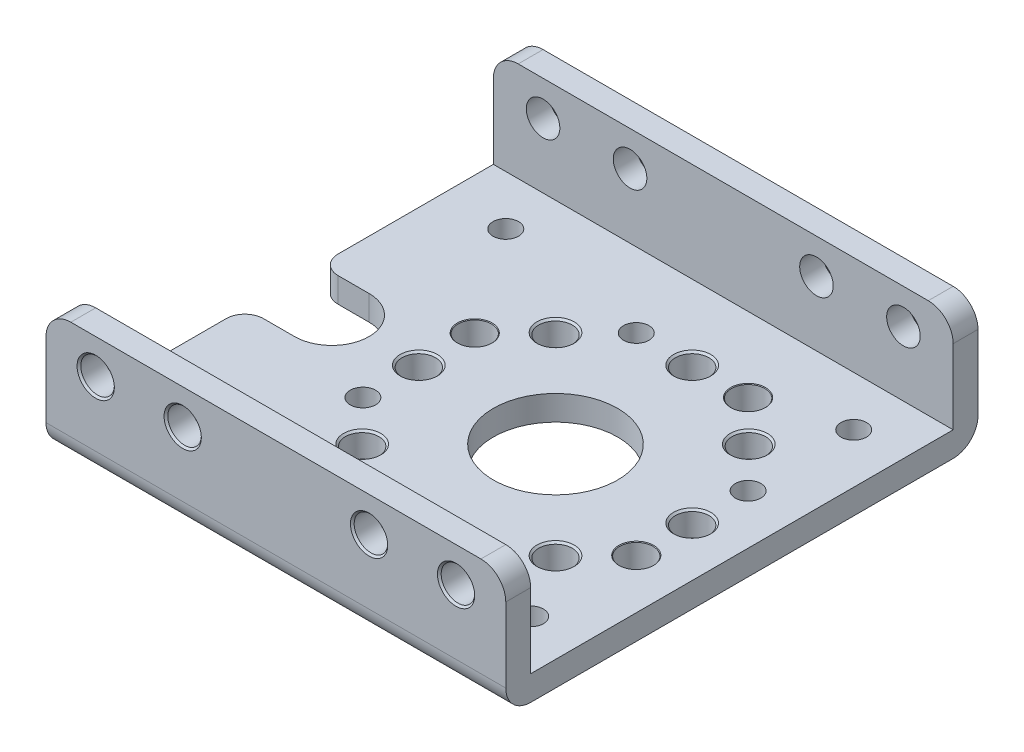
from build123d import *

# Parameters (mm, degrees)
SKETCH1_W           = 37
SKETCH1_H           = 38
BOSS_EXTRUDE1_DEPTH = 10
SKETCH2_W           = 34
SKETCH2_H           = 8
CUT_EXTRUDE1_DEPTH  = 38
CUT_EXTRUDE2_DEPTH  = 3
HOLE1_D             = 2.05
HOLE1_DEPTH         = 10
HOLE2_D             = 2.05
HOLE2_DEPTH         = 10
HOLE3_D             = 2.05
HOLE3_DEPTH         = 10
HOLE4_D             = 2.05
HOLE4_DEPTH         = 10
HOLE5_D             = 2.05
HOLE5_DEPTH         = 10
HOLE6_D             = 2.05
HOLE6_DEPTH         = 10
HOLE7_D             = 2.05
HOLE7_DEPTH         = 10
HOLE8_D             = 2.05
HOLE8_DEPTH         = 10
HOLE9_D             = 10
HOLE9_DEPTH         = 10
HOLE10_D            = 2.7
HOLE10_DEPTH        = 2
HOLE11_D            = 2.7
HOLE11_DEPTH        = 2
HOLE12_D            = 2.7
HOLE12_DEPTH        = 2
HOLE13_D            = 2.7
HOLE13_DEPTH        = 2
HOLE14_D            = 2.7
HOLE14_DEPTH        = 2
HOLE15_D            = 2.7
HOLE15_DEPTH        = 2
HOLE16_D            = 2.7
HOLE16_DEPTH        = 2
HOLE17_D            = 2.7
HOLE17_DEPTH        = 2
HOLE18_D            = 2.7
HOLE18_DEPTH        = 2
HOLE19_D            = 2.7
HOLE19_DEPTH        = 2
HOLE20_D            = 2.7
HOLE20_DEPTH        = 2
HOLE21_D            = 2.7
HOLE21_DEPTH        = 2
HOLE22_D            = 2.7
HOLE22_DEPTH        = 2
HOLE23_D            = 2.7
HOLE23_DEPTH        = 2
HOLE24_D            = 2.7
HOLE24_DEPTH        = 2
HOLE25_D            = 2.7
HOLE25_DEPTH        = 2
HOLE26_D            = 2.7
HOLE26_DEPTH        = 38
HOLE27_D            = 2.7
HOLE27_DEPTH        = 38
HOLE28_D            = 2.7
HOLE28_DEPTH        = 38
HOLE29_D            = 2.7
HOLE29_DEPTH        = 38
CHAMFER1_SIZE       = 0.15
CHAMFER2_SIZE       = 0.15
CHAMFER3_SIZE       = 0.15
CHAMFER4_SIZE       = 0.15
CHAMFER5_SIZE       = 0.15
CHAMFER6_SIZE       = 0.15
CHAMFER7_SIZE       = 0.15
CHAMFER8_SIZE       = 0.15
CHAMFER9_SIZE       = 0.15
CHAMFER10_SIZE      = 0.15
CHAMFER11_SIZE      = 0.15
CHAMFER12_SIZE      = 0.05
CHAMFER13_SIZE      = 0.375
CHAMFER14_SIZE      = 0.05
CHAMFER15_SIZE      = 0.375
CHAMFER16_SIZE      = 0.15
CHAMFER17_SIZE      = 0.375
CHAMFER18_SIZE      = 0.325
CHAMFER19_SIZE      = 0.375
CHAMFER20_SIZE      = 0.15
CHAMFER21_SIZE      = 0.325
CHAMFER22_SIZE      = 0.05
CHAMFER23_SIZE      = 0.325
CHAMFER24_SIZE      = 0.15
CHAMFER25_SIZE      = 0.325
CHAMFER26_SIZE      = 0.05
CHAMFER27_SIZE      = 0.15
CHAMFER28_SIZE      = 0.15
FILLET1_R           = 1.5
FILLET2_R           = 1.5
FILLET3_R           = 2
FILLET4_R           = 2
FILLET5_R           = 2
FILLET6_R           = 2
FILLET7_R           = 2
FILLET8_R           = 2


with BuildPart() as part:
    # Sketch1 → Boss-Extrude1 (new body)
    with BuildSketch(Plane(origin=(0, 10, 0), x_dir=(-1, 0, 0), z_dir=(0, 1, 0))):
        with Locations((3.5, 0)):
            Rectangle(SKETCH1_W, SKETCH1_H)
    extrude(amount=-BOSS_EXTRUDE1_DEPTH)

    # Sketch2 → Cut-Extrude1 (cut, through all)
    with BuildSketch(Plane(origin=(15, 0, 0), x_dir=(0, 0, -1), z_dir=(1, 0, 0))):
        with Locations((0, 6)):
            Rectangle(SKETCH2_W, SKETCH2_H)
    extrude(amount=-CUT_EXTRUDE1_DEPTH, mode=Mode.SUBTRACT)

    # Sketch3 → Cut-Extrude2 (cut, through all)
    with BuildSketch(Plane(origin=(0, 2, 0), x_dir=(-1, 0, 0), z_dir=(0, 1, 0))):
        with BuildLine():
            Line((22, -3), (22, 3))
            Line((22, 3), (18, 3))
            ThreePointArc((18, 3), (15, 0), (18, -3))
            Line((18, -3), (22, -3))
        make_face()
    extrude(amount=-CUT_EXTRUDE2_DEPTH, mode=Mode.SUBTRACT)

    # Hole1
    with Locations(Plane.XZ):
        with Locations((-4.5, -11)):
            Hole(HOLE1_D / 2, depth=HOLE1_DEPTH)

    # Hole2
    with Locations(Plane.XZ):
        with Locations((-11, 4.5)):
            Hole(HOLE2_D / 2, depth=HOLE2_DEPTH)

    # Hole3
    with Locations(Plane.XZ):
        with Locations((4.5, 11)):
            Hole(HOLE3_D / 2, depth=HOLE3_DEPTH)

    # Hole4
    with Locations(Plane.XZ):
        with Locations((11, -4.5)):
            Hole(HOLE4_D / 2, depth=HOLE4_DEPTH)

    # Hole5
    with Locations(Plane.XZ):
        with Locations((-17, 13)):
            Hole(HOLE5_D / 2, depth=HOLE5_DEPTH)

    # Hole6
    with Locations(Plane.XZ):
        with Locations((-17, -13)):
            Hole(HOLE6_D / 2, depth=HOLE6_DEPTH)

    # Hole7
    with Locations(Plane.XZ):
        with Locations((11, 13)):
            Hole(HOLE7_D / 2, depth=HOLE7_DEPTH)

    # Hole8
    with Locations(Plane.XZ):
        with Locations((11, -13)):
            Hole(HOLE8_D / 2, depth=HOLE8_DEPTH)

    # Hole9
    with Locations(Plane.XZ):
        with Locations((0, 0)):
            Hole(HOLE9_D / 2, depth=HOLE9_DEPTH)

    # Hole10
    with Locations(Plane(origin=(0, 2, 0), x_dir=(-1, 0, 0), z_dir=(0, 1, 0))):
        with Locations((11, -4.5)):
            Hole(HOLE10_D / 2, depth=HOLE10_DEPTH)

    # Hole11
    with Locations(Plane(origin=(0, 2, 0), x_dir=(-1, 0, 0), z_dir=(0, 1, 0))):
        with Locations((4.5, 11)):
            Hole(HOLE11_D / 2, depth=HOLE11_DEPTH)

    # Hole12
    with Locations(Plane(origin=(0, 2, 0), x_dir=(-1, 0, 0), z_dir=(0, 1, 0))):
        with Locations((-11, 4.5)):
            Hole(HOLE12_D / 2, depth=HOLE12_DEPTH)

    # Hole13
    with Locations(Plane(origin=(0, 2, 0), x_dir=(-1, 0, 0), z_dir=(0, 1, 0))):
        with Locations((-4.5, -11)):
            Hole(HOLE13_D / 2, depth=HOLE13_DEPTH)

    # Hole14
    with Locations(Plane(origin=(0, 2, 0), x_dir=(-1, 0, 0), z_dir=(0, 1, 0))):
        with Locations((-7.778174593, 7.778174593)):
            Hole(HOLE14_D / 2, depth=HOLE14_DEPTH)

    # Hole15
    with Locations(Plane(origin=(0, 2, 0), x_dir=(-1, 0, 0), z_dir=(0, 1, 0))):
        with Locations((0, 11)):
            Hole(HOLE15_D / 2, depth=HOLE15_DEPTH)

    # Hole16
    with Locations(Plane(origin=(0, 2, 0), x_dir=(-1, 0, 0), z_dir=(0, 1, 0))):
        with Locations((7.778174593, 7.778174593)):
            Hole(HOLE16_D / 2, depth=HOLE16_DEPTH)

    # Hole17
    with Locations(Plane(origin=(0, 2, 0), x_dir=(-1, 0, 0), z_dir=(0, 1, 0))):
        with Locations((11, 0)):
            Hole(HOLE17_D / 2, depth=HOLE17_DEPTH)

    # Hole18
    with Locations(Plane(origin=(0, 2, 0), x_dir=(-1, 0, 0), z_dir=(0, 1, 0))):
        with Locations((7.778174593, -7.778174593)):
            Hole(HOLE18_D / 2, depth=HOLE18_DEPTH)

    # Hole19
    with Locations(Plane(origin=(0, 2, 0), x_dir=(-1, 0, 0), z_dir=(0, 1, 0))):
        with Locations((0, -11)):
            Hole(HOLE19_D / 2, depth=HOLE19_DEPTH)

    # Hole20
    with Locations(Plane(origin=(0, 2, 0), x_dir=(-1, 0, 0), z_dir=(0, 1, 0))):
        with Locations((-7.778174593, -7.778174593)):
            Hole(HOLE20_D / 2, depth=HOLE20_DEPTH)

    # Hole21
    with Locations(Plane(origin=(0, 2, 0), x_dir=(-1, 0, 0), z_dir=(0, 1, 0))):
        with Locations((-11, 0)):
            Hole(HOLE21_D / 2, depth=HOLE21_DEPTH)

    # Hole22
    with Locations(Plane.XY.offset(19)):
        with Locations((-11, 7.2)):
            Hole(HOLE22_D / 2, depth=HOLE22_DEPTH)

    # Hole23
    with Locations(Plane.XY.offset(19)):
        with Locations((11, 7.2)):
            Hole(HOLE23_D / 2, depth=HOLE23_DEPTH)

    # Hole24
    with Locations(Plane.XY.offset(19)):
        with Locations((-18, 7.2)):
            Hole(HOLE24_D / 2, depth=HOLE24_DEPTH)

    # Hole25
    with Locations(Plane.XY.offset(19)):
        with Locations((4, 7.2)):
            Hole(HOLE25_D / 2, depth=HOLE25_DEPTH)

    # Hole26
    with Locations(Plane(origin=(0, 0, -19), x_dir=(-1, 0, 0), z_dir=(0, 0, -1))):
        with Locations((11, 7.2)):
            Hole(HOLE26_D / 2, depth=HOLE26_DEPTH)

    # Hole27
    with Locations(Plane(origin=(0, 0, -19), x_dir=(-1, 0, 0), z_dir=(0, 0, -1))):
        with Locations((-11, 7.2)):
            Hole(HOLE27_D / 2, depth=HOLE27_DEPTH)

    # Hole28
    with Locations(Plane(origin=(0, 0, -19), x_dir=(-1, 0, 0), z_dir=(0, 0, -1))):
        with Locations((18, 7.2)):
            Hole(HOLE28_D / 2, depth=HOLE28_DEPTH)

    # Hole29
    with Locations(Plane(origin=(0, 0, -19), x_dir=(-1, 0, 0), z_dir=(0, 0, -1))):
        with Locations((-4, 7.2)):
            Hole(HOLE29_D / 2, depth=HOLE29_DEPTH)

    # Chamfer1
    chamfer1_edges = [part.edges().sort_by_distance(p)[0] for p in [
        (6.428174593, 2, -7.778174593),
    ]]
    chamfer(chamfer1_edges, length=CHAMFER1_SIZE)

    # Chamfer2
    chamfer2_edges = [part.edges().sort_by_distance(p)[0] for p in [
        (2.65, 7.2, -19),
    ]]
    chamfer(chamfer2_edges, length=CHAMFER2_SIZE)

    # Chamfer3
    chamfer3_edges = [part.edges().sort_by_distance(p)[0] for p in [
        (9.65, 2, 0),
    ]]
    chamfer(chamfer3_edges, length=CHAMFER3_SIZE)

    # Chamfer4
    chamfer4_edges = [part.edges().sort_by_distance(p)[0] for p in [
        (-12.35, 2, 0),
    ]]
    chamfer(chamfer4_edges, length=CHAMFER4_SIZE)

    # Chamfer5
    chamfer5_edges = [part.edges().sort_by_distance(p)[0] for p in [
        (-9.128174593, 2, -7.778174593),
    ]]
    chamfer(chamfer5_edges, length=CHAMFER5_SIZE)

    # Chamfer6
    chamfer6_edges = [part.edges().sort_by_distance(p)[0] for p in [
        (-9.65, 7.2, 19),
    ]]
    chamfer(chamfer6_edges, length=CHAMFER6_SIZE)

    # Chamfer7
    chamfer7_edges = [part.edges().sort_by_distance(p)[0] for p in [
        (-1.35, 2, -11),
    ]]
    chamfer(chamfer7_edges, length=CHAMFER7_SIZE)

    # Chamfer8
    chamfer8_edges = [part.edges().sort_by_distance(p)[0] for p in [
        (-16.65, 7.2, 19),
    ]]
    chamfer(chamfer8_edges, length=CHAMFER8_SIZE)

    # Chamfer9
    chamfer9_edges = [part.edges().sort_by_distance(p)[0] for p in [
        (9.65, 7.2, -19),
    ]]
    chamfer(chamfer9_edges, length=CHAMFER9_SIZE)

    # Chamfer10
    chamfer10_edges = [part.edges().sort_by_distance(p)[0] for p in [
        (-12.35, 7.2, -19),
    ]]
    chamfer(chamfer10_edges, length=CHAMFER10_SIZE)

    # Chamfer11
    chamfer11_edges = [part.edges().sort_by_distance(p)[0] for p in [
        (-19.35, 7.2, -19),
    ]]
    chamfer(chamfer11_edges, length=CHAMFER11_SIZE)

    # Chamfer12
    chamfer12_edges = [part.edges().sort_by_distance(p)[0] for p in [
        (-5.85, 2, 11),
    ]]
    chamfer(chamfer12_edges, length=CHAMFER12_SIZE)

    # Chamfer13
    chamfer13_edges = [part.edges().sort_by_distance(p)[0] for p in [
        (-3.475, 0, -11),
    ]]
    chamfer(chamfer13_edges, length=CHAMFER13_SIZE)

    # Chamfer14
    chamfer14_edges = [part.edges().sort_by_distance(p)[0] for p in [
        (3.15, 2, -11),
    ]]
    chamfer(chamfer14_edges, length=CHAMFER14_SIZE)

    # Chamfer15
    chamfer15_edges = [part.edges().sort_by_distance(p)[0] for p in [
        (-9.975, 0, 4.5),
    ]]
    chamfer(chamfer15_edges, length=CHAMFER15_SIZE)

    # Chamfer16
    chamfer16_edges = [part.edges().sort_by_distance(p)[0] for p in [
        (-1.35, 2, 11),
    ]]
    chamfer(chamfer16_edges, length=CHAMFER16_SIZE)

    # Chamfer17
    chamfer17_edges = [part.edges().sort_by_distance(p)[0] for p in [
        (5.525, 0, 11),
    ]]
    chamfer(chamfer17_edges, length=CHAMFER17_SIZE)

    # Chamfer18
    chamfer18_edges = [part.edges().sort_by_distance(p)[0] for p in [
        (12.025, 0, -13),
    ]]
    chamfer(chamfer18_edges, length=CHAMFER18_SIZE)

    # Chamfer19
    chamfer19_edges = [part.edges().sort_by_distance(p)[0] for p in [
        (12.025, 0, -4.5),
    ]]
    chamfer(chamfer19_edges, length=CHAMFER19_SIZE)

    # Chamfer20
    chamfer20_edges = [part.edges().sort_by_distance(p)[0] for p in [
        (5.35, 7.2, 19),
    ]]
    chamfer(chamfer20_edges, length=CHAMFER20_SIZE)

    # Chamfer21
    chamfer21_edges = [part.edges().sort_by_distance(p)[0] for p in [
        (-15.975, 0, 13),
    ]]
    chamfer(chamfer21_edges, length=CHAMFER21_SIZE)

    # Chamfer22
    chamfer22_edges = [part.edges().sort_by_distance(p)[0] for p in [
        (9.65, 2, 4.5),
    ]]
    chamfer(chamfer22_edges, length=CHAMFER22_SIZE)

    # Chamfer23
    chamfer23_edges = [part.edges().sort_by_distance(p)[0] for p in [
        (-15.975, 0, -13),
    ]]
    chamfer(chamfer23_edges, length=CHAMFER23_SIZE)

    # Chamfer24
    chamfer24_edges = [part.edges().sort_by_distance(p)[0] for p in [
        (-9.128174593, 2, 7.778174593),
    ]]
    chamfer(chamfer24_edges, length=CHAMFER24_SIZE)

    # Chamfer25
    chamfer25_edges = [part.edges().sort_by_distance(p)[0] for p in [
        (12.025, 0, 13),
    ]]
    chamfer(chamfer25_edges, length=CHAMFER25_SIZE)

    # Chamfer26
    chamfer26_edges = [part.edges().sort_by_distance(p)[0] for p in [
        (-12.35, 2, -4.5),
    ]]
    chamfer(chamfer26_edges, length=CHAMFER26_SIZE)

    # Chamfer27
    chamfer27_edges = [part.edges().sort_by_distance(p)[0] for p in [
        (12.35, 7.2, 19),
    ]]
    chamfer(chamfer27_edges, length=CHAMFER27_SIZE)

    # Chamfer28
    chamfer28_edges = [part.edges().sort_by_distance(p)[0] for p in [
        (6.428174593, 2, 7.778174593),
    ]]
    chamfer(chamfer28_edges, length=CHAMFER28_SIZE)

    # Fillet1
    fillet1_edges = [part.edges().sort_by_distance(p)[0] for p in [
        (-22, 1, -3),
    ]]
    fillet(fillet1_edges, radius=FILLET1_R)

    # Fillet2
    fillet2_edges = [part.edges().sort_by_distance(p)[0] for p in [
        (-22, 1, 3),
    ]]
    fillet(fillet2_edges, radius=FILLET2_R)

    # Fillet3
    fillet3_edges = [part.edges().sort_by_distance(p)[0] for p in [
        (-3.5, 0, -19),
    ]]
    fillet(fillet3_edges, radius=FILLET3_R)

    # Fillet4
    fillet4_edges = [part.edges().sort_by_distance(p)[0] for p in [
        (15, 10, 18),
    ]]
    fillet(fillet4_edges, radius=FILLET4_R)

    # Fillet5
    fillet5_edges = [part.edges().sort_by_distance(p)[0] for p in [
        (-22, 10, 18),
    ]]
    fillet(fillet5_edges, radius=FILLET5_R)

    # Fillet6
    fillet6_edges = [part.edges().sort_by_distance(p)[0] for p in [
        (-22, 10, -18),
    ]]
    fillet(fillet6_edges, radius=FILLET6_R)

    # Fillet7
    fillet7_edges = [part.edges().sort_by_distance(p)[0] for p in [
        (15, 10, -18),
    ]]
    fillet(fillet7_edges, radius=FILLET7_R)

    # Fillet8
    fillet8_edges = [part.edges().sort_by_distance(p)[0] for p in [
        (-3.5, 0, 19),
    ]]
    fillet(fillet8_edges, radius=FILLET8_R)


solid = part.part
